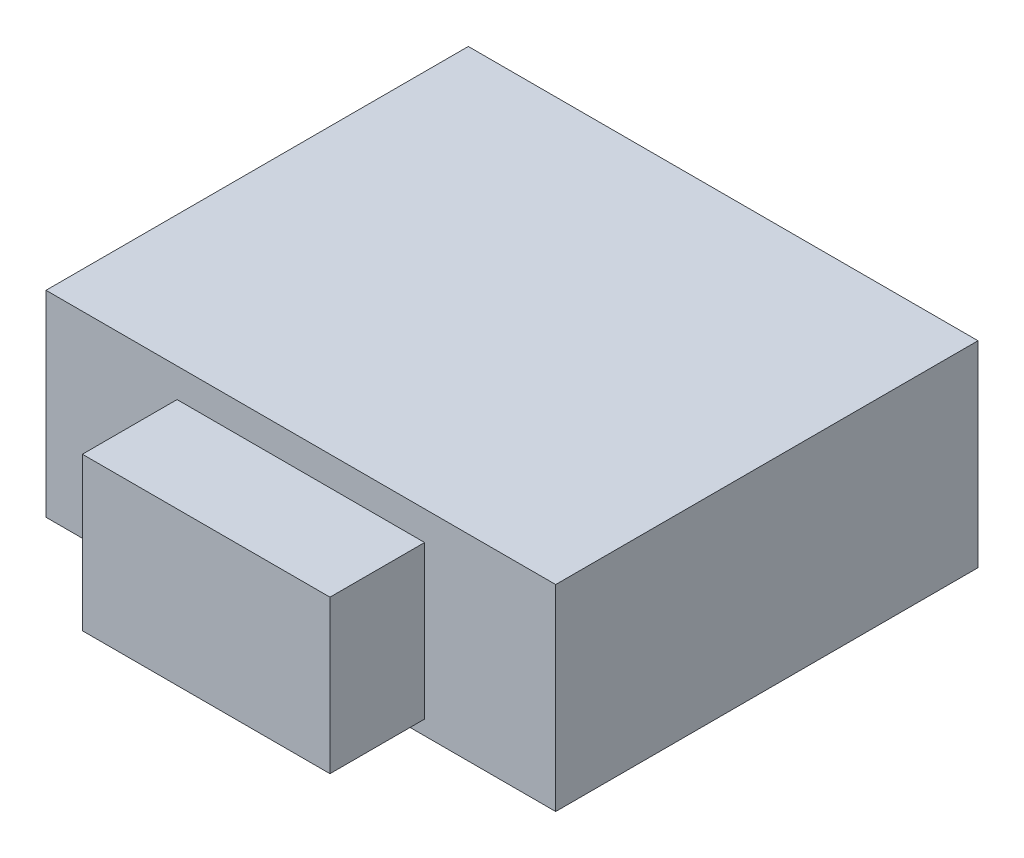
from build123d import *

# Parameters (mm, degrees)
SKETCH1_W           = 3.5
SKETCH1_H           = 1.35
BOSS_EXTRUDE1_DEPTH = 2.9
SKETCH2_W           = 1.7
SKETCH2_H           = 1.05
BOSS_EXTRUDE2_DEPTH = 0.65


with BuildPart() as part:
    # Sketch1 → Boss-Extrude1 (new body)
    with BuildSketch(Plane(origin=(0, 0, 0), x_dir=(1, 0, 0), z_dir=(0, 0, -1))):
        with Locations((0, 0.675)):
            Rectangle(SKETCH1_W, SKETCH1_H)
    extrude(amount=BOSS_EXTRUDE1_DEPTH)

    # Sketch2 → Boss-Extrude2 (add)
    with BuildSketch(Plane.XY):
        with Locations((0, -0.725)):
            Rectangle(SKETCH2_W, SKETCH2_H)
    extrude(amount=BOSS_EXTRUDE2_DEPTH)


solid = part.part
